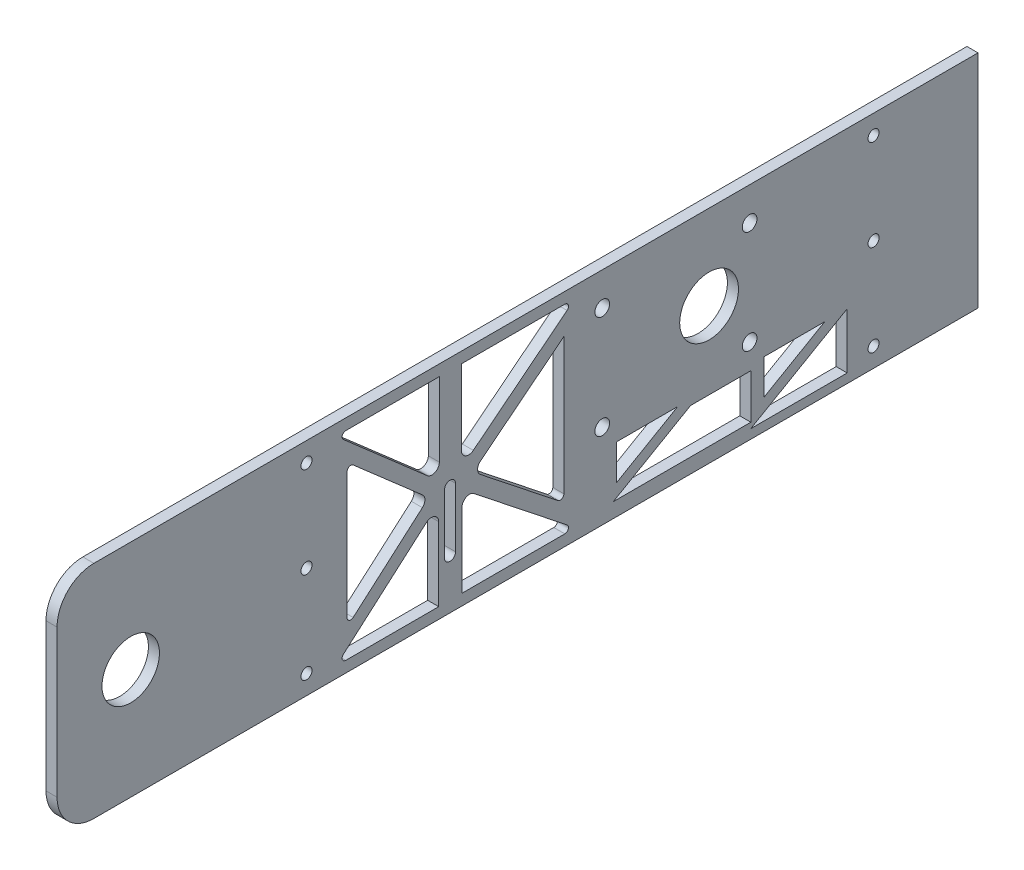
from build123d import *

# Parameters (mm, degrees)
SKETCH1_W           = 3
SKETCH1_H           = 60
BOSS_EXTRUDE1_DEPTH = 250
FILLET1_R           = 10
FILLET2_R           = 10
SKETCH2_R           = 4.25
CUT_EXTRUDE1_DEPTH  = 4
SKETCH5_R           = 7.8
CUT_EXTRUDE4_DEPTH  = 4
SKETCH13_R          = 7.98
CUT_EXTRUDE10_DEPTH = 4
SKETCH14_R          = 2
CUT_EXTRUDE11_DEPTH = 4
CUT_EXTRUDE14_DEPTH = 10
FILLET3_R           = 1
FILLET4_R           = 2
CUT_EXTRUDE18_DEPTH = 10
CUT_EXTRUDE19_DEPTH = 4
SKETCH20_R          = 1.499999993
SKETCH20_R_2        = 1.5
CUT_EXTRUDE20_DEPTH = 4


with BuildPart() as part:
    # Sketch1 → Boss-Extrude1 (new body)
    with BuildSketch(Plane.XY):
        Rectangle(SKETCH1_W, SKETCH1_H)
    extrude(amount=BOSS_EXTRUDE1_DEPTH)

    # Fillet1
    fillet1_edges = [part.edges().sort_by_distance(p)[0] for p in [
        (0, 30, 250),
    ]]
    fillet(fillet1_edges, radius=FILLET1_R)

    # Fillet2
    fillet2_edges = [part.edges().sort_by_distance(p)[0] for p in [
        (0, -30, 250),
    ]]
    fillet(fillet2_edges, radius=FILLET2_R)

    # Sketch2 → Cut-Extrude1 (cut, through all)
    with BuildSketch(Plane.ZY.offset(1.5)):
        with Locations((230, 0)):
            Circle(SKETCH2_R)
    extrude(amount=-CUT_EXTRUDE1_DEPTH, mode=Mode.SUBTRACT)

    # Sketch5 → Cut-Extrude4 (cut, through all)
    with BuildSketch(Plane.ZY.offset(1.5)):
        with Locations((230, 0)):
            Circle(SKETCH5_R)
    extrude(amount=-CUT_EXTRUDE4_DEPTH, mode=Mode.SUBTRACT)

    # Sketch13 → Cut-Extrude10 (cut, through all)
    with BuildSketch(Plane.ZY.offset(1.5)):
        with Locations((73, 7)):
            Circle(SKETCH13_R)
    extrude(amount=-CUT_EXTRUDE10_DEPTH, mode=Mode.SUBTRACT)

    # Sketch14 → Cut-Extrude11 (cut, through all)
    with BuildSketch(Plane(origin=(1.5, 0, 0), x_dir=(0, 0, -1), z_dir=(1, 0, 0))):
        with Locations((-102, -7)):
            Circle(SKETCH14_R)
        with Locations((-102, 21)):
            Circle(SKETCH14_R)
        with Locations((-62, 21)):
            Circle(SKETCH14_R)
        with Locations((-62, -7)):
            Circle(SKETCH14_R)
    extrude(amount=-CUT_EXTRUDE11_DEPTH, mode=Mode.SUBTRACT)

    # Sketch17 → Cut-Extrude14 (cut)
    with BuildSketch(Plane.ZY.offset(1.5)):
        Polygon((149.1019184, 0), (171.275987572, -19.368578167), (171.275987572, 19.368578167), align=None)
        Polygon((146.3902575, -27), (174.288564399, -27), (146.3902575, -2.631421833), align=None)
        Polygon((109.288564399, -27), (140.055353087, -27), (140.055353087, -2.631421833), align=None)
        Polygon((112.424175394, 19.516465485), (112.424175394, -19.516465485), (137.064881363, 0), align=None)
        Polygon((109.288564399, 27), (140.242069678, 2.483534515), (140.242069678, 27), align=None)
        Polygon((146.220949067, 2.483534515), (174.288564399, 27), (146.220949067, 27), align=None)
    extrude(amount=-CUT_EXTRUDE14_DEPTH, mode=Mode.SUBTRACT)

    # Fillet3
    fillet3_edges = [part.edges().sort_by_distance(p)[0] for p in [
        (0, -27, 174.288564399),
        (0, 27, 174.288564399),
        (0, -19.368578167, 171.275987572),
        (0, 19.368578167, 171.275987572),
        (0, -19.516465485, 112.424175394),
        (0, 27, 109.288564399),
        (0, -27, 109.288564399),
    ]]
    fillet(fillet3_edges, radius=FILLET3_R)

    # Fillet4
    fillet4_edges = [part.edges().sort_by_distance(p)[0] for p in [
        (0, -2.631421833, 146.3902575),
        (0, 2.483534515, 146.220949067),
        (0, 0, 149.1019184),
        (0, 0, 137.064881363),
        (0, 2.483534515, 140.242069678),
        (0, -2.631421833, 140.055353087),
    ]]
    fillet(fillet4_edges, radius=FILLET4_R)

    # Sketch18 → Cut-Extrude18 (cut)
    with BuildSketch(Plane.ZY.offset(1.5)):
        Polygon((61.668054604, -26), (98.988380185, -26), (78.023904982, -13.896154598), (61.668054604, -13.896154598), align=None)
        Polygon((98.086456396, -21.955043464), (98.086456396, -12.396154598), (81.529975217, -12.396154598), align=None)
        Polygon((58.14382401, -12.396154598), (41.612161756, -12.396154598), (58.14382401, -21.940994237), align=None)
        Polygon((35.508194368, -27.5), (61.668054604, -27.5), (35.508194368, -12.396154598), align=None)
    extrude(amount=-CUT_EXTRUDE18_DEPTH, mode=Mode.SUBTRACT)

    # Sketch19 → Cut-Extrude19 (cut, through all)
    with BuildSketch(Plane.ZY.offset(1.5)):
        with BuildLine():
            Line((144.8152575, -0.290513908), (144.8152575, -16.383557477))
            ThreePointArc((144.8152575, -16.383557477), (143.3152575, -17.883557477), (141.8152575, -16.383557477))
            Line((141.8152575, -16.383557477), (141.8152575, -0.290513908))
            ThreePointArc((141.8152575, -0.290513908), (143.3152575, 1.209486092), (144.8152575, -0.290513908))
        make_face()
    extrude(amount=-CUT_EXTRUDE19_DEPTH, mode=Mode.SUBTRACT)

    # Sketch20 → Cut-Extrude20 (cut, through all)
    with BuildSketch(Plane.ZY.offset(1.5)):
        with Locations((28.351822222, -24.750000002)):
            Circle(SKETCH20_R)
        with Locations((28.351822222, -2e-09)):
            Circle(SKETCH20_R)
        with Locations((28.351822222, 24.749999998)):
            Circle(SKETCH20_R)
        with Locations((182.288564399, -24.750000007)):
            Circle(SKETCH20_R_2)
        with Locations((182.288564399, -7e-09)):
            Circle(SKETCH20_R_2)
        with Locations((182.288564399, 24.749999993)):
            Circle(SKETCH20_R_2)
    extrude(amount=-CUT_EXTRUDE20_DEPTH, mode=Mode.SUBTRACT)


solid = part.part
